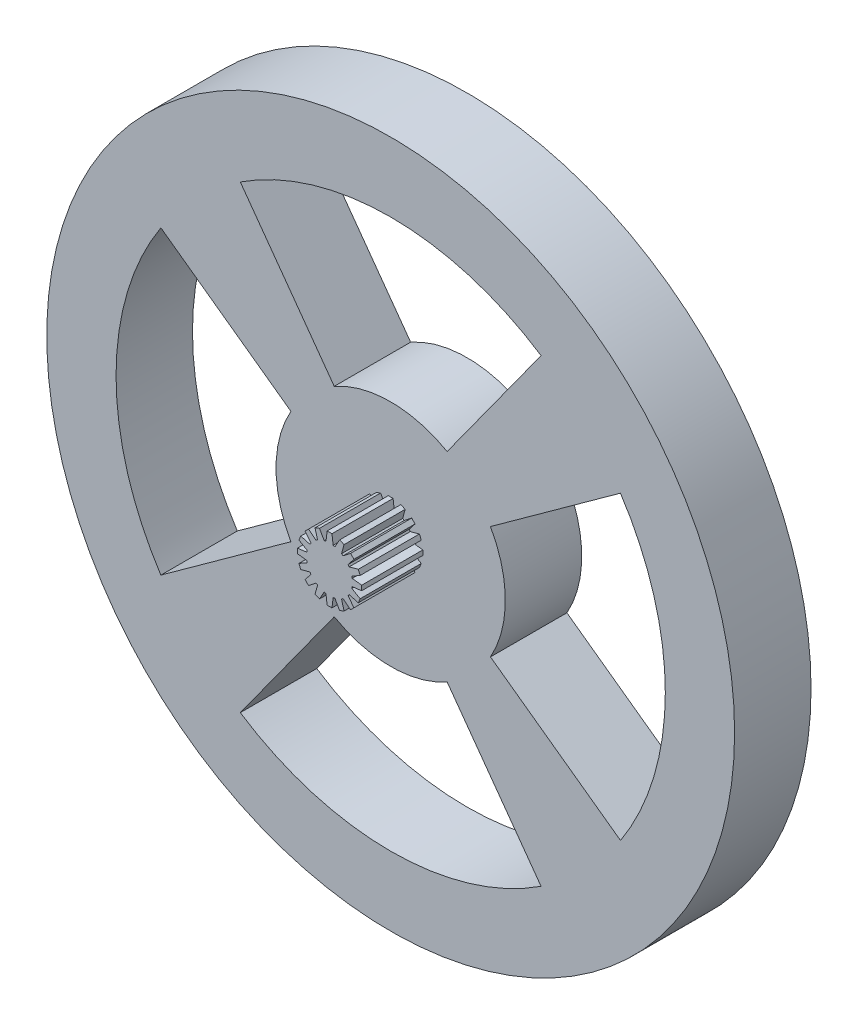
from build123d import *

# Parameters (mm, degrees)
ESBO_O1_R                = 45
RESSALTO_EXTRUS_O1_DEPTH = 10
CORTE_EXTRUS_O1_DEPTH    = 10
PADR_OCIRCULAR1_COUNT    = 4
ESBO_O3_R                = 3
RESSALTO_EXTRUS_O2_DEPTH = 8
RESSALTO_EXTRUS_O3_DEPTH = 8
PADR_OCIRCULAR2_COUNT    = 16


with BuildPart() as part:
    # Esboço1 → Ressalto-extrusão1 (new body)
    with BuildSketch(Plane.XY):
        Circle(ESBO_O1_R)
    extrude(amount=RESSALTO_EXTRUS_O1_DEPTH)

    # Esboço2 → Corte-extrusão1 (cut)
    with BuildSketch(Plane.XY.offset(10)):
        with BuildLine():
            Line((-19.67582712, 30.066816509), (-7.386402319, 13.055307763))
            ThreePointArc((-7.386402319, 13.055307763), (0, 15), (7.386402319, 13.055307763))
            Line((7.386402319, 13.055307763), (19.67582712, 30.066816509))
            ThreePointArc((19.67582712, 30.066816509), (0, 35.932598401), (-19.67582712, 30.066816509))
        make_face()
    corte_extrus_o1 = extrude(amount=-CORTE_EXTRUS_O1_DEPTH, mode=Mode.SUBTRACT)

    # PadrãoCircular1: Corte-extrusão1 ×4 about axis
    padr_ocircular1_axis = Axis((0, 0, 0), (0, 0, 1))
    for i in range(1, PADR_OCIRCULAR1_COUNT):
        add(corte_extrus_o1.rotate(padr_ocircular1_axis, i * 360 / PADR_OCIRCULAR1_COUNT), mode=Mode.SUBTRACT)

    # Esboço3 → Ressalto-extrusão2 (add)
    with BuildSketch(Plane.XY.offset(10)):
        Circle(ESBO_O3_R)
    extrude(amount=RESSALTO_EXTRUS_O2_DEPTH)

    # Esboço4 → Ressalto-extrusão3 (add)
    with BuildSketch(Plane.XY.offset(18)):
        Polygon((-0.5, 2.695095519), (0.5, 2.695095519), (0.314812798, 4.203324244), (-0.314812798, 4.203324244), align=None)
    ressalto_extrus_o3 = extrude(amount=-RESSALTO_EXTRUS_O3_DEPTH)

    # PadrãoCircular2: Ressalto-extrusão3 ×16 about axis
    padr_ocircular2_axis = Axis((0, 0, 0), (0, 0, 1))
    for i in range(1, PADR_OCIRCULAR2_COUNT):
        add(ressalto_extrus_o3.rotate(padr_ocircular2_axis, i * 360 / PADR_OCIRCULAR2_COUNT))


solid = part.part
